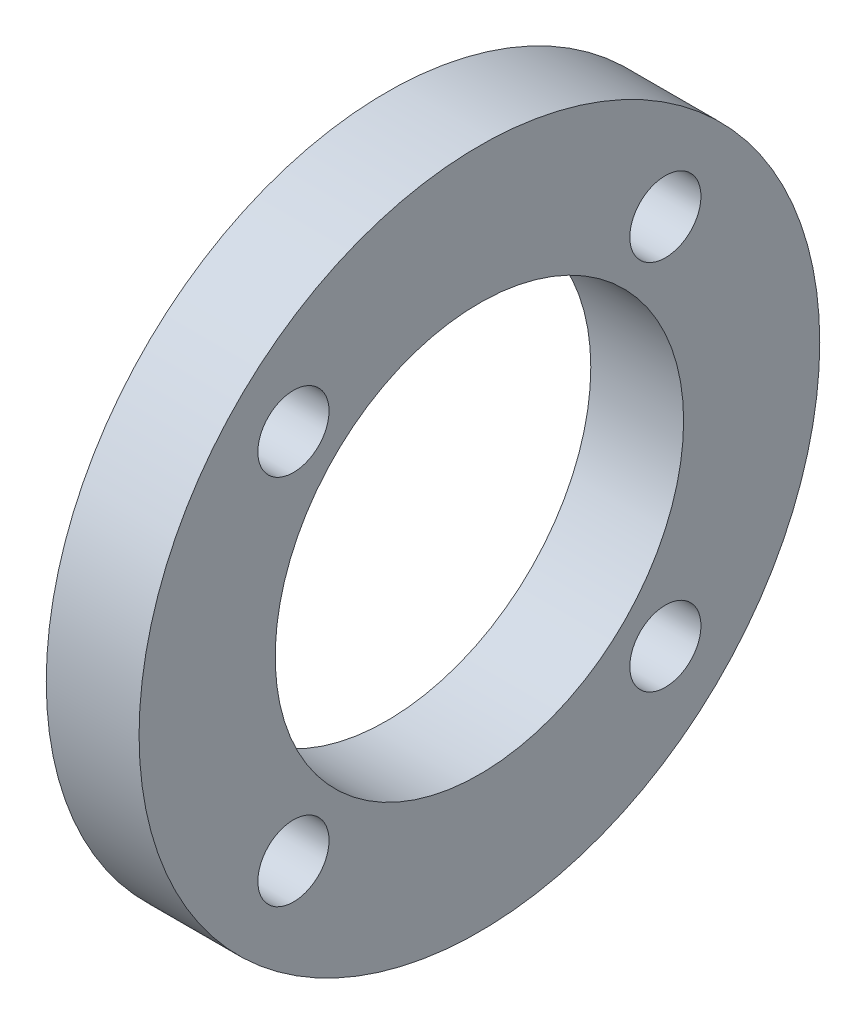
from build123d import *

# Parameters (mm, degrees)
SKETCH2_R           = 11
SKETCH2_R_2         = 6.6
BOSS_EXTRUDE1_DEPTH = 3
SKETCH3_R           = 1.15
CUT_EXTRUDE1_DEPTH  = 4


with BuildPart() as part:
    # Sketch2 → Boss-Extrude1 (new body)
    with BuildSketch(Plane(origin=(0, 0, 0), x_dir=(0, 0, -1), z_dir=(1, 0, 0))):
        Circle(SKETCH2_R)
        Circle(SKETCH2_R_2, mode=Mode.SUBTRACT)
    extrude(amount=BOSS_EXTRUDE1_DEPTH)

    # Sketch3 → Cut-Extrude1 (cut, through all)
    with BuildSketch(Plane(origin=(0, 0, 0), x_dir=(0, 0, -1), z_dir=(1, 0, 0))):
        with Locations((6.01040764, 6.01040764)):
            Circle(SKETCH3_R)
        with Locations((6.01040764, -6.01040764)):
            Circle(SKETCH3_R)
        with Locations((-6.01040764, -6.01040764)):
            Circle(SKETCH3_R)
        with Locations((-6.01040764, 6.01040764)):
            Circle(SKETCH3_R)
    extrude(amount=CUT_EXTRUDE1_DEPTH, mode=Mode.SUBTRACT)


solid = part.part
